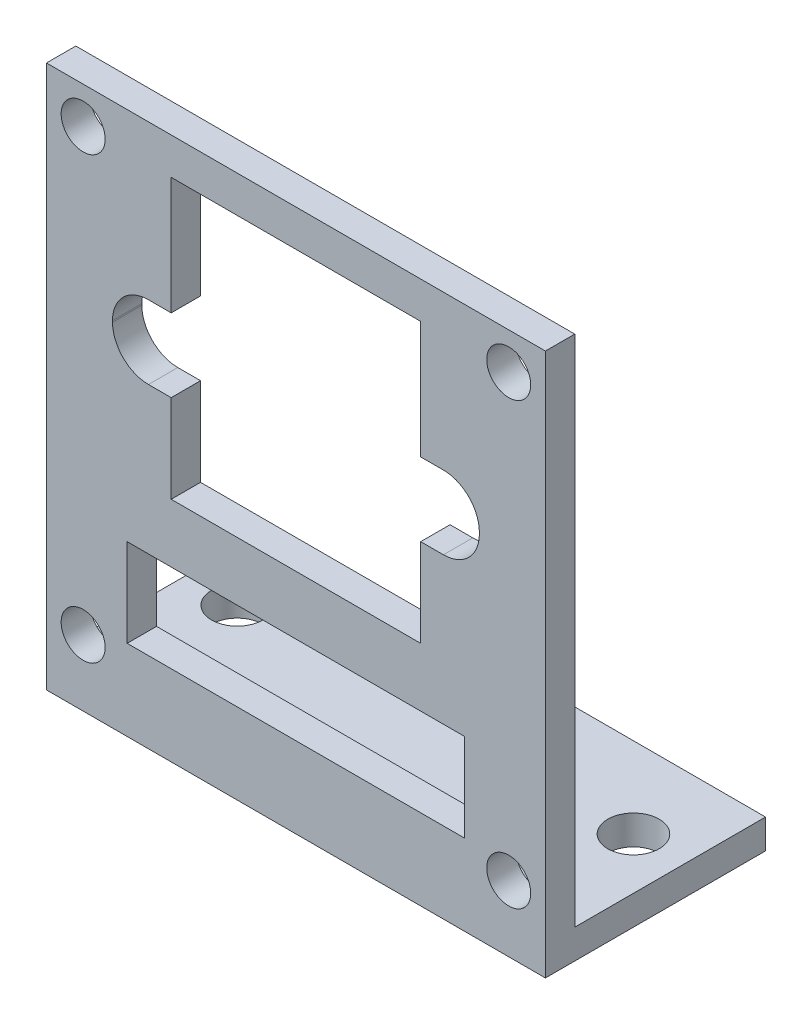
from build123d import *

# Parameters (mm, degrees)
ESBO_O1_W                = 34
ESBO_O1_H                = 35
ESBO_O1_R                = 1.5
ESBO_O1_W_2              = 23
ESBO_O1_H_2              = 6
RESSALTO_EXTRUS_O1_DEPTH = 2
ESBO_O2_W                = 34
ESBO_O2_H                = 2
RESSALTO_EXTRUS_O2_DEPTH = 15
ESBO_O3_R                = 1.75
CORTE_EXTRUS_O1_DEPTH    = 15


with BuildPart() as part:
    # Esboço1 → Ressalto-extrusão1 (new body)
    with BuildSketch(Plane.XY):
        with Locations((-5.310292873, -3.170678153)):
            Rectangle(ESBO_O1_W, ESBO_O1_H)
        with Locations((-19.810292873, 11.829321847)):
            Circle(ESBO_O1_R, mode=Mode.SUBTRACT)
        with Locations((9.189707127, 11.829321847)):
            Circle(ESBO_O1_R, mode=Mode.SUBTRACT)
        with Locations((-19.810292873, -18.170678153)):
            Circle(ESBO_O1_R, mode=Mode.SUBTRACT)
        with Locations((9.189707127, -18.170678153)):
            Circle(ESBO_O1_R, mode=Mode.SUBTRACT)
        with BuildLine():
            Line((-13.810292873, -1.170678153), (-13.810292873, -7.170678153))
            Line((-13.810292873, -7.170678153), (3.189707127, -7.170678153))
            Line((3.189707127, -7.170678153), (3.189707127, -1.170678153))
            Line((3.189707127, -1.170678153), (4.739707127, -1.170678153))
            ThreePointArc((4.739707127, -1.170678153), (6.472118741, -0.453089767), (7.189707127, 1.279321847))
            Line((7.189707127, 1.279321847), (7.189707127, 1.379321847))
            ThreePointArc((7.189707127, 1.379321847), (6.472118741, 3.11173346), (4.739707127, 3.829321847))
            Line((4.739707127, 3.829321847), (3.189707127, 3.829321847))
            Line((3.189707127, 3.829321847), (3.189707127, 11.829321847))
            Line((3.189707127, 11.829321847), (-13.810292873, 11.829321847))
            Line((-13.810292873, 11.829321847), (-13.810292873, 3.829321847))
            Line((-13.810292873, 3.829321847), (-15.360292873, 3.829321847))
            ThreePointArc((-15.360292873, 3.829321847), (-17.092704487, 3.11173346), (-17.810292873, 1.379321847))
            Line((-17.810292873, 1.379321847), (-17.810292873, 1.279321847))
            ThreePointArc((-17.810292873, 1.279321847), (-17.092704487, -0.453089767), (-15.360292873, -1.170678153))
            Line((-15.360292873, -1.170678153), (-13.810292873, -1.170678153))
        make_face(mode=Mode.SUBTRACT)
        with Locations((-5.310292873, -14.170678153)):
            Rectangle(ESBO_O1_W_2, ESBO_O1_H_2, mode=Mode.SUBTRACT)
    extrude(amount=RESSALTO_EXTRUS_O1_DEPTH)

    # Esboço2 → Ressalto-extrusão2 (add)
    with BuildSketch(Plane.XY.offset(2)):
        with Locations((-5.310292873, -21.670678153)):
            Rectangle(ESBO_O2_W, ESBO_O2_H)
    extrude(amount=-RESSALTO_EXTRUS_O2_DEPTH)

    # Esboço3 → Corte-extrusão1 (cut)
    with BuildSketch(Plane(origin=(0, -20.670678153, 0), x_dir=(1, 0, 0), z_dir=(0, 1, 0))):
        with Locations((8.189707127, 7.5)):
            Circle(ESBO_O3_R)
        with Locations((-18.810292873, 7.5)):
            Circle(ESBO_O3_R)
    extrude(amount=-CORTE_EXTRUS_O1_DEPTH, mode=Mode.SUBTRACT)


solid = part.part
